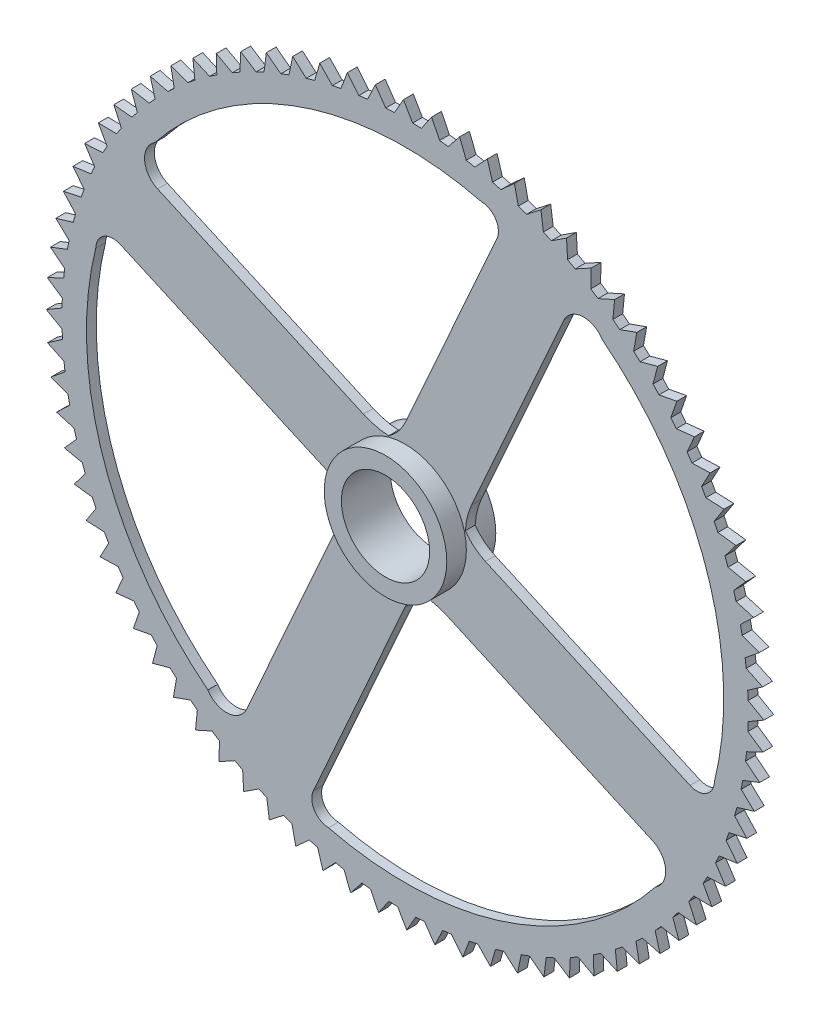
from build123d import *

# Parameters (mm, degrees)
SKETCH1_R           = 12.5
BOSS_EXTRUDE4_DEPTH = 1
SKETCH2_R           = 12.5
BOSS_EXTRUDE6_DEPTH = 5
SKETCH3_R           = 9
CUT_EXTRUDE1_DEPTH  = 11
BOSS_EXTRUDE7_DEPTH = 2
CIRPATTERN1_COUNT   = 80


with BuildPart() as part:
    # Sketch1 → Boss-Extrude4 (new body, symmetric)
    with BuildSketch(Plane.XY):
        with BuildLine():
            ThreePointArc((70, 0), (49.497474683, 49.497474683), (0, 70))
            ThreePointArc((0, 70), (-49.497474683, -49.497474683), (70, 0))
        make_face()
        with BuildLine():
            ThreePointArc((15.626967974, 63.093564426), (16.404763945, 62.98151231), (17.138390716, 62.699884878))
            ThreePointArc((17.138390716, 62.699884878), (27.821779459, 58.744774982), (37.650577373, 52.985224577))
            ThreePointArc((37.650577373, 52.985224577), (39.124828962, 52.257608291), (40.238159899, 51.047923444))
            ThreePointArc((40.238159899, 51.047923444), (58.482819671, 28.368288691), (65, 0))
            ThreePointArc((65, 0), (64.521630821, -7.871413861), (63.093564426, -15.626967974))
            ThreePointArc((63.093564426, -15.626967974), (62.98151231, -16.404763945), (62.699884878, -17.138390716))
            ThreePointArc((62.699884878, -17.138390716), (58.744774982, -27.821779459), (52.985224577, -37.650577373))
            ThreePointArc((52.985224577, -37.650577373), (52.257608291, -39.124828962), (51.047923444, -40.238159899))
            ThreePointArc((51.047923444, -40.238159899), (21.077319578, -61.487776016), (-15.626967974, -63.093564426))
            ThreePointArc((-15.626967974, -63.093564426), (-16.404763945, -62.98151231), (-17.138390716, -62.699884878))
            ThreePointArc((-17.138390716, -62.699884878), (-27.821779459, -58.744774982), (-37.650577373, -52.985224577))
            ThreePointArc((-37.650577373, -52.985224577), (-39.124828962, -52.257608291), (-40.238159899, -51.047923444))
            ThreePointArc((-40.238159899, -51.047923444), (-61.487776016, -21.077319578), (-63.093564426, 15.626967974))
            ThreePointArc((-63.093564426, 15.626967974), (-62.98151231, 16.404763945), (-62.699884878, 17.138390716))
            ThreePointArc((-62.699884878, 17.138390716), (-58.744774982, 27.821779459), (-52.985224577, 37.650577373))
            ThreePointArc((-52.985224577, 37.650577373), (-52.257608291, 39.124828962), (-51.047923444, 40.238159899))
            ThreePointArc((-51.047923444, 40.238159899), (-21.077319578, 61.487776016), (15.626967974, 63.093564426))
        make_face(mode=Mode.SUBTRACT)
        with BuildLine():
            Line((18.732932786, 58.131440257), (0.041855041, 16.378296087))
            ThreePointArc((0.041855041, 16.378296087), (-1.373403878, 14.104065487), (-3.34672983, 12.29269382))
            ThreePointArc((-3.34672983, 12.29269382), (-5.984661616, 12.679229486), (-8.507682006, 13.540891856))
            Line((-8.507682006, 13.540891856), (-50.498595537, 32.338408666))
            ThreePointArc((-50.498595537, 32.338408666), (-52.72969057, 34.532112429), (-52.985224577, 37.650577373))
            ThreePointArc((-52.985224577, 37.650577373), (-58.744774982, 27.821779459), (-62.699884878, 17.138390716))
            ThreePointArc((-62.699884878, 17.138390716), (-60.732586477, 18.843664969), (-58.131440257, 18.732932786))
            Line((-58.131440257, 18.732932786), (-16.378296087, 0.041855041))
            ThreePointArc((-16.378296087, 0.041855041), (-14.104065487, -1.373403878), (-12.29269382, -3.34672983))
            ThreePointArc((-12.29269382, -3.34672983), (-12.679229486, -5.984661616), (-13.540891856, -8.507682006))
            Line((-13.540891856, -8.507682006), (-32.338408666, -50.498595537))
            ThreePointArc((-32.338408666, -50.498595537), (-34.532112429, -52.72969057), (-37.650577373, -52.985224577))
            ThreePointArc((-37.650577373, -52.985224577), (-27.821779459, -58.744774982), (-17.138390716, -62.699884878))
            ThreePointArc((-17.138390716, -62.699884878), (-18.843664969, -60.732586477), (-18.732932786, -58.131440257))
            Line((-18.732932786, -58.131440257), (-0.041855041, -16.378296087))
            ThreePointArc((-0.041855041, -16.378296087), (1.373403878, -14.104065487), (3.34672983, -12.29269382))
            ThreePointArc((3.34672983, -12.29269382), (5.984661616, -12.679229486), (8.507682006, -13.540891856))
            Line((8.507682006, -13.540891856), (50.498595537, -32.338408666))
            ThreePointArc((50.498595537, -32.338408666), (52.72969057, -34.532112429), (52.985224577, -37.650577373))
            ThreePointArc((52.985224577, -37.650577373), (58.744774982, -27.821779459), (62.699884878, -17.138390716))
            ThreePointArc((62.699884878, -17.138390716), (60.732586477, -18.843664969), (58.131440257, -18.732932786))
            Line((58.131440257, -18.732932786), (16.378296087, -0.041855041))
            ThreePointArc((16.378296087, -0.041855041), (14.104065487, 1.373403878), (12.29269382, 3.34672983))
            ThreePointArc((12.29269382, 3.34672983), (12.679229486, 5.984661616), (13.540891856, 8.507682006))
            Line((13.540891856, 8.507682006), (32.338408666, 50.498595537))
            ThreePointArc((32.338408666, 50.498595537), (34.532112429, 52.72969057), (37.650577373, 52.985224577))
            ThreePointArc((37.650577373, 52.985224577), (27.821779459, 58.744774982), (17.138390716, 62.699884878))
            ThreePointArc((17.138390716, 62.699884878), (18.843664969, 60.732586477), (18.732932786, 58.131440257))
        make_face()
        Circle(SKETCH1_R, mode=Mode.SUBTRACT)
    extrude(amount=BOSS_EXTRUDE4_DEPTH, both=True)

    # Sketch2 → Boss-Extrude6 (add, symmetric)
    with BuildSketch(Plane.XY):
        Circle(SKETCH2_R)
    extrude(amount=BOSS_EXTRUDE6_DEPTH, both=True)

    # Sketch3 → Cut-Extrude1 (cut, through all)
    with BuildSketch(Plane.XY.offset(5)):
        Circle(SKETCH3_R)
    extrude(amount=-CUT_EXTRUDE1_DEPTH, mode=Mode.SUBTRACT)

    # Sketch4 → Boss-Extrude7 (add)
    with BuildSketch(Plane.XY.offset(1)):
        Polygon((-69.579857055, -7.657903908), (-72.940933789, -6.073415967), (-69.888188613, -3.954882101), align=None)
    boss_extrude7 = extrude(amount=-BOSS_EXTRUDE7_DEPTH)

    # CirPattern1: Boss-Extrude7 ×80 about axis
    cirpattern1_axis = Axis((0, 0, 0), (0, 0, 1))
    for i in range(1, CIRPATTERN1_COUNT):
        add(boss_extrude7.rotate(cirpattern1_axis, i * 360 / CIRPATTERN1_COUNT))


solid = part.part
